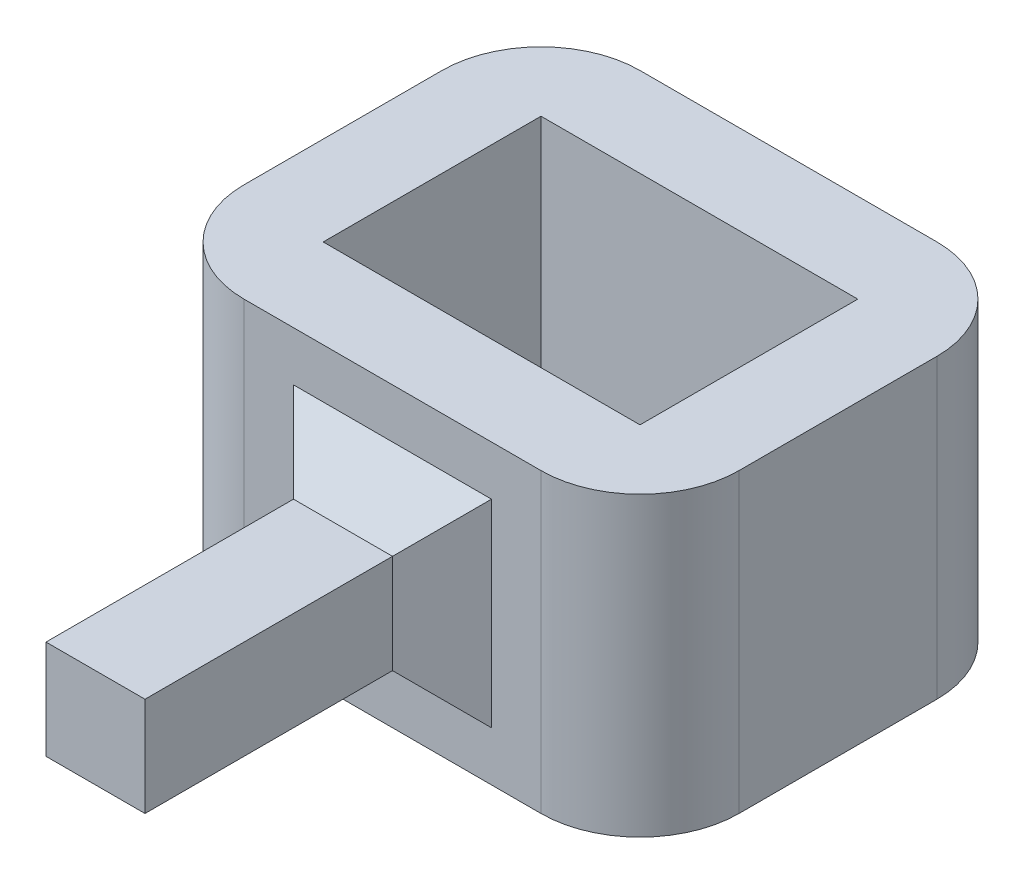
from build123d import *

# Parameters (mm, degrees)
SKETCH1_W           = 50
SKETCH1_H           = 40
SKETCH1_W_2         = 32
SKETCH1_H_2         = 22
BOSS_EXTRUDE1_DEPTH = 30
SKETCH2_W           = 10
SKETCH2_H           = 10
BOSS_EXTRUDE2_DEPTH = 30
CHAMFER1_SIZE       = 5
FILLET1_R           = 10


with BuildPart() as part:
    # Sketch1 → Boss-Extrude1 (new body)
    with BuildSketch(Plane(origin=(0, 0, 0), x_dir=(1, 0, 0), z_dir=(0, 1, 0))):
        with Locations((1.8704784, -7.860892388)):
            Rectangle(SKETCH1_W, SKETCH1_H)
        with Locations((1.8704784, -7.860892388)):
            Rectangle(SKETCH1_W_2, SKETCH1_H_2, mode=Mode.SUBTRACT)
    extrude(amount=BOSS_EXTRUDE1_DEPTH)

    # Sketch2 → Boss-Extrude2 (add)
    with BuildSketch(Plane.XY.offset(27.860892388)):
        with Locations((1.8704784, 15)):
            Rectangle(SKETCH2_W, SKETCH2_H)
    extrude(amount=BOSS_EXTRUDE2_DEPTH)

    # Chamfer1
    chamfer1_edges = [part.edges().sort_by_distance(p)[0] for p in [
        (1.8704784, 10, 27.860892388),
        (6.8704784, 15, 27.860892388),
        (-3.1295216, 15, 27.860892388),
        (1.8704784, 20, 27.860892388),
    ]]
    chamfer(chamfer1_edges, length=CHAMFER1_SIZE)

    # Fillet1
    fillet1_edges = [part.edges().sort_by_distance(p)[0] for p in [
        (26.8704784, 15, 27.860892388),
        (-23.1295216, 15, 27.860892388),
        (-23.1295216, 15, -12.139107612),
        (26.8704784, 15, -12.139107612),
    ]]
    fillet(fillet1_edges, radius=FILLET1_R)


solid = part.part
